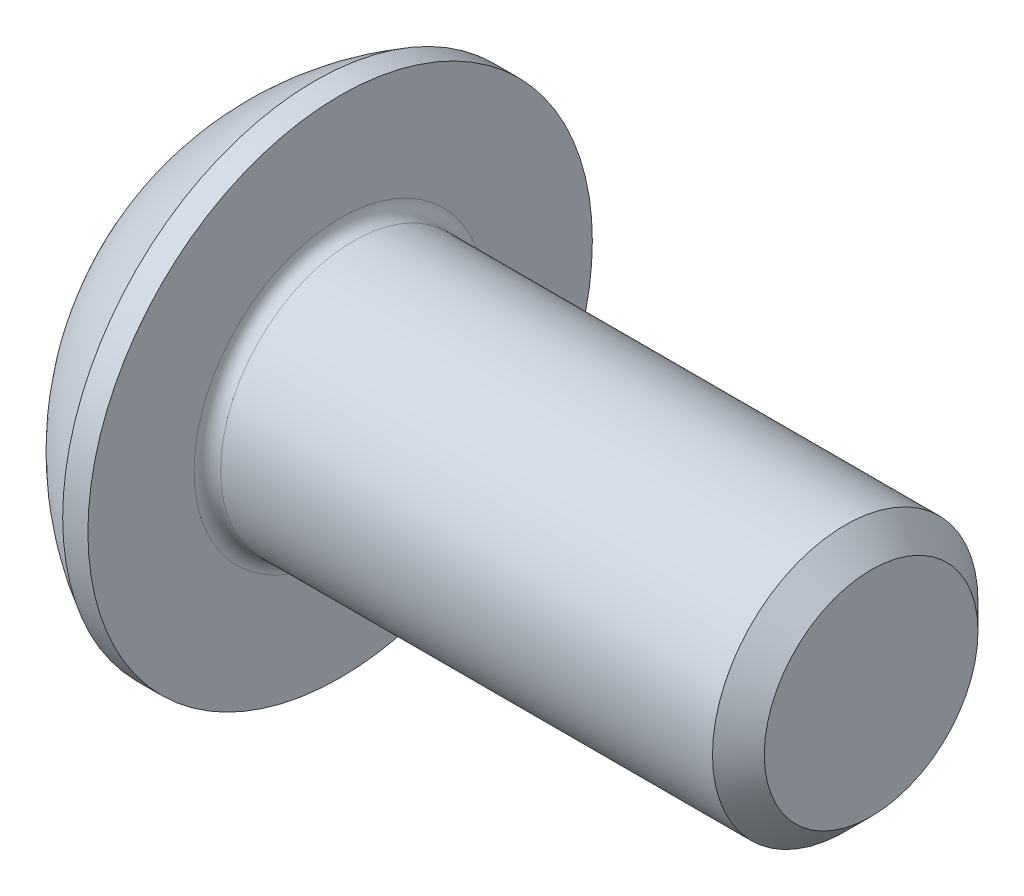
from build123d import *

# Parameters (mm, degrees)
FILLET1_R   = 0.2
HEX_2_DEPTH = 1.3


with BuildPart() as part:
    # BodySke → BaseBody (revolve)
    with BuildSketch(Plane.XY):
        with BuildLine():
            Line((10.2, 0), (10.2, 1.61))
            Line((10.2, 1.61), (9.81, 2))
            Line((9.81, 2), (2.2, 2))
            Line((2.2, 2), (2.2, 3.8))
            Line((2.2, 3.8), (1.82, 3.8))
            ThreePointArc((1.82, 3.8), (0.762013659, 2.991755338), (0, 1.9))
            Line((0, 1.9), (0, 0))
            Line((0, 0), (10.2, 0))
        make_face()
    revolve(axis=Axis((0, 0, 0), (1, 0, 0)))

    # Fillet1
    fillet1_edges = [part.edges().sort_by_distance(p)[0] for p in [
        (2.2, -2, 0),
    ]]
    fillet(fillet1_edges, radius=FILLET1_R)

    # Sketch2 → PreBroach (revolve, cut)
    with BuildSketch(Plane.XY):
        Polygon((0, 1.25), (1.3, 1.25), (2.021687836, 0), (0, 0), align=None)
    revolve(axis=Axis((0, 0, 0), (1, 0, 0)), mode=Mode.SUBTRACT)

    # Sketch3 → Hex 2 (cut)
    with BuildSketch(Plane(origin=(0, 0, 0), x_dir=(0, 0, -1), z_dir=(1, 0, 0))):
        Polygon((-1.25, -0.721687836), (-1.25, 0.721687836), (0, 1.443375673), (1.25, 0.721687836), (1.25, -0.721687836), (0, -1.443375673), align=None)
    extrude(amount=HEX_2_DEPTH, mode=Mode.SUBTRACT)


solid = part.part
